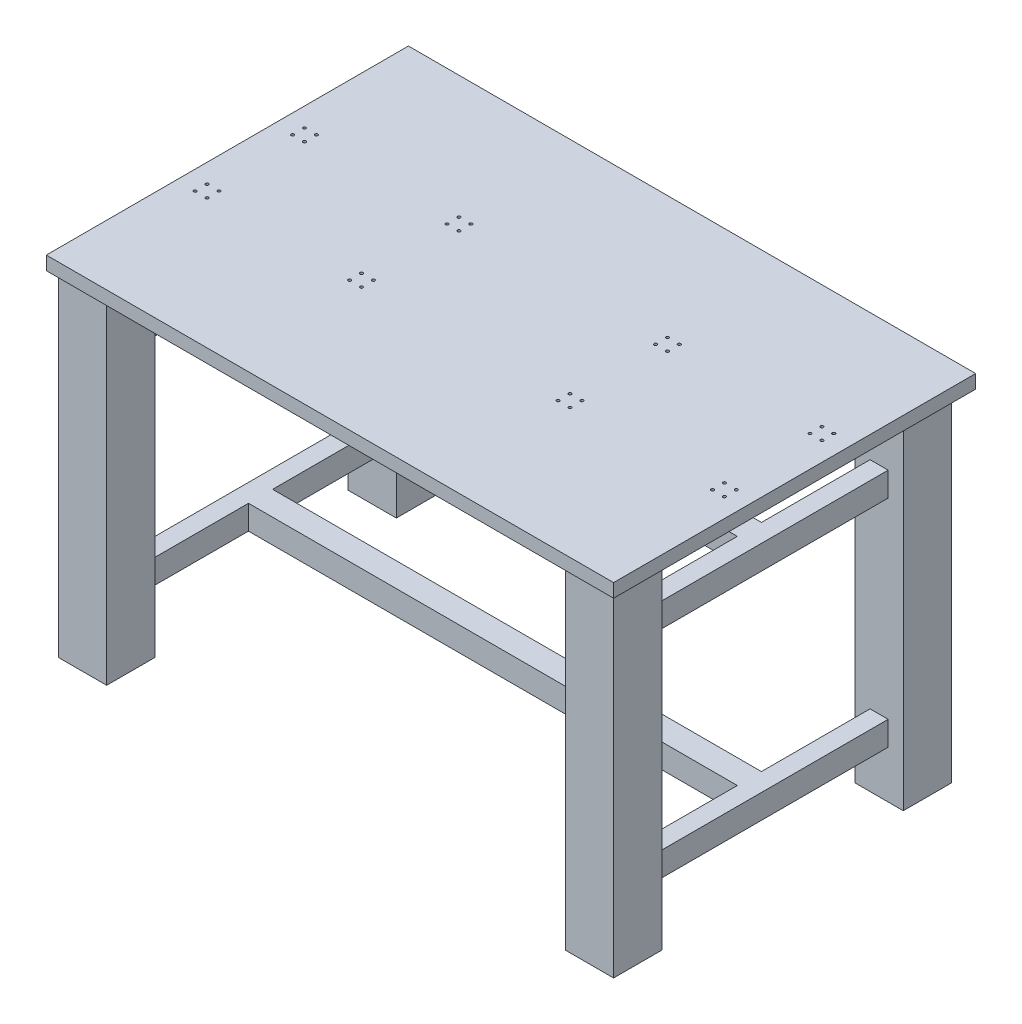
from build123d import *

# Parameters (mm, degrees)
SKETCH1_W               = 1028.7
SKETCH1_H               = 50.8
BOSS_EXTRUDE1_DEPTH     = 704.85
SKETCH2_W               = 508
SKETCH2_H               = 100
SKETCH2_H_2             = 403.25
CUT_EXTRUDE1_DEPTH      = 585.2
CUT_EXTRUDE1_DEPTH_BACK = 585.2
SKETCH3_W               = 1193.8
SKETCH3_H               = 762
BOSS_EXTRUDE2_DEPTH     = 28.5
SKETCH4_R               = 3.1
CUT_EXTRUDE2_DEPTH      = 28.5


with BuildPart() as part:
    # Sketch1 → Boss-Extrude1 (new body)
    with BuildSketch(Plane(origin=(0, 0, 0), x_dir=(1, 0, 0), z_dir=(0, 1, 0))):
        Polygon((-584.2, 355.6), (-584.2, 254), (-552.45, 254), (-514.35, 254), (-482.6, 254), (-482.6, 355.6), align=None)
        Polygon((584.2, 355.6), (482.6, 355.6), (482.6, 254), (514.35, 254), (552.45, 254), (584.2, 254), align=None)
        Polygon((482.6, -254), (482.6, -355.6), (584.2, -355.6), (584.2, -254), (552.45, -254), (514.35, -254), align=None)
        Polygon((-552.45, -254), (-584.2, -254), (-584.2, -355.6), (-482.6, -355.6), (-482.6, -254), (-514.35, -254), align=None)
        Polygon((-514.35, 254), (-552.45, 254), (-552.45, -254), (-514.35, -254), (-514.35, -25.4), (-514.35, 25.4), align=None)
        Rectangle(SKETCH1_W, SKETCH1_H)
        Polygon((514.35, 254), (514.35, 25.4), (514.35, -25.4), (514.35, -254), (552.45, -254), (552.45, 254), align=None)
    extrude(amount=-BOSS_EXTRUDE1_DEPTH)

    # Sketch2 → Cut-Extrude1 (cut, two sides)
    with BuildSketch(Plane(origin=(0, 0, 0), x_dir=(0, 0, -1), z_dir=(1, 0, 0))) as cut_extrude1_sk:
        with Locations((0, -50)):
            Rectangle(SKETCH2_W, SKETCH2_H)
        with Locations((0, -352.425)):
            Rectangle(SKETCH2_W, SKETCH2_H_2)
        with Locations((0, -654.85)):
            Rectangle(SKETCH2_W, SKETCH2_H)
    extrude(amount=CUT_EXTRUDE1_DEPTH, mode=Mode.SUBTRACT)
    extrude(cut_extrude1_sk.sketch, amount=-CUT_EXTRUDE1_DEPTH_BACK, mode=Mode.SUBTRACT)


with BuildPart() as body_2:
    # Sketch3 → Boss-Extrude2 (new body)
    with BuildSketch(Plane(origin=(0, 0, 0), x_dir=(1, 0, 0), z_dir=(0, 1, 0))):
        with Locations((0, 12.7)):
            Rectangle(SKETCH3_W, SKETCH3_H)
    extrude(amount=BOSS_EXTRUDE2_DEPTH)

    # Sketch4 → Cut-Extrude2 (cut)
    with BuildSketch(Plane(origin=(0, 28.5, 0), x_dir=(1, 0, 0), z_dir=(0, 1, 0))):
        with Locations((-556.9, 110)):
            Circle(SKETCH4_R)
        with Locations((-531.9, 110)):
            Circle(SKETCH4_R)
        with Locations((-531.9, 135)):
            Circle(SKETCH4_R)
        with Locations((-556.9, 135)):
            Circle(SKETCH4_R)
        with Locations((-231.9, 135)):
            Circle(SKETCH4_R)
        with Locations((-206.9, 135)):
            Circle(SKETCH4_R)
        with Locations((-231.9, 110)):
            Circle(SKETCH4_R)
        with Locations((-206.9, 110)):
            Circle(SKETCH4_R)
        with Locations((-206.9, -70)):
            Circle(SKETCH4_R)
        with Locations((-231.9, -70)):
            Circle(SKETCH4_R)
        with Locations((-231.9, -95)):
            Circle(SKETCH4_R)
        with Locations((-206.9, -95)):
            Circle(SKETCH4_R)
        with Locations((-531.9, -70)):
            Circle(SKETCH4_R)
        with Locations((-531.9, -95)):
            Circle(SKETCH4_R)
        with Locations((-556.9, -70)):
            Circle(SKETCH4_R)
        with Locations((-556.9, -95)):
            Circle(SKETCH4_R)
    cut_extrude2 = extrude(amount=-CUT_EXTRUDE2_DEPTH, mode=Mode.SUBTRACT)

    # Mirror1: Cut-Extrude2 across plane
    add(cut_extrude2.mirror(Plane(origin=(0, 0, 0), x_dir=(0, 0, 1), z_dir=(1, 0, 0))), mode=Mode.SUBTRACT)


solid = Compound([part.part, body_2.part])
